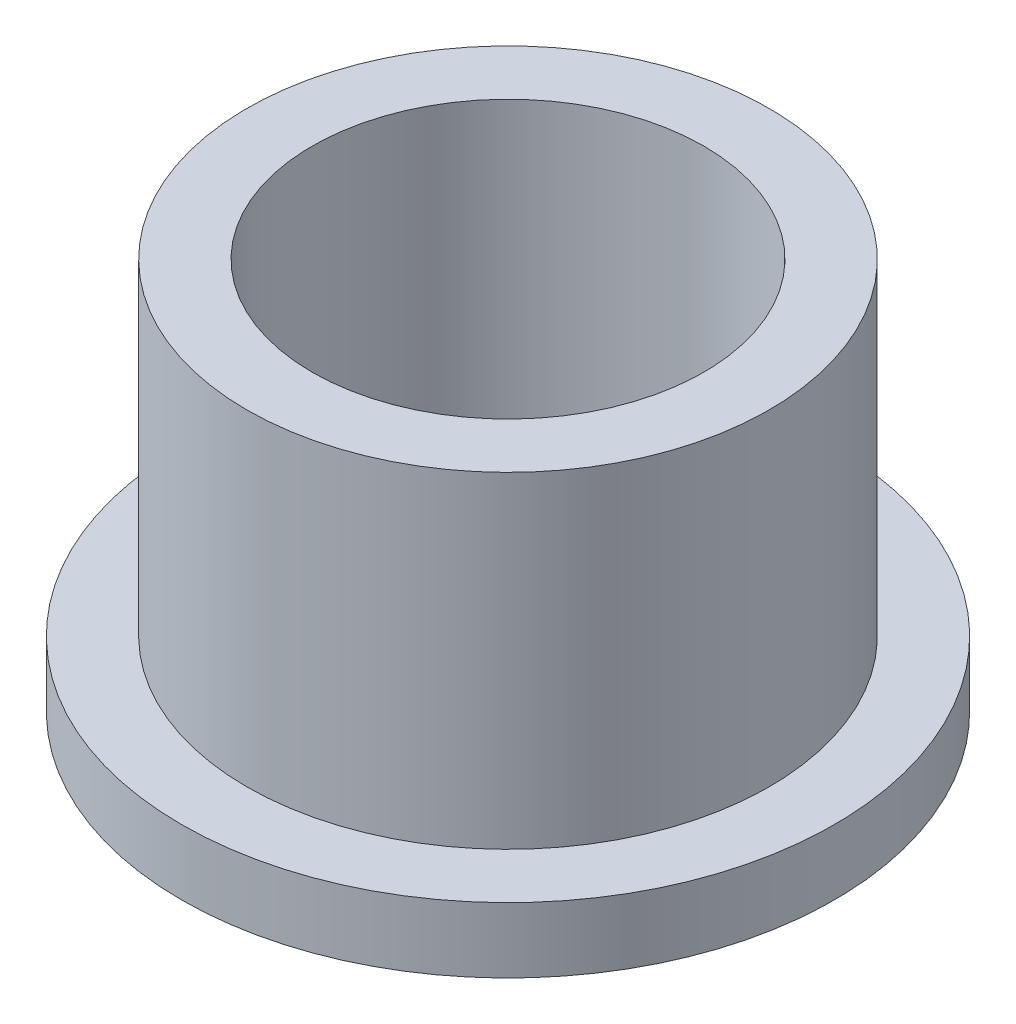
from build123d import *

# Parameters (mm, degrees)
TUBE_R              = 6.35
BOSS_EXTRUDE1_DEPTH = 9.525
FLANGE_R            = 7.9375
BOSS_EXTRUDE2_DEPTH = 1.5875
SHAFT_R             = 4.7625
CUT_EXTRUDE1_DEPTH  = 9.5875


with BuildPart() as part:
    # tube → Boss-Extrude1 (new body)
    with BuildSketch(Plane(origin=(0, 0, 0), x_dir=(1, 0, 0), z_dir=(0, 1, 0))):
        Circle(TUBE_R)
    extrude(amount=BOSS_EXTRUDE1_DEPTH)

    # Flange → Boss-Extrude2 (add)
    with BuildSketch(Plane(origin=(0, 0, 0), x_dir=(1, 0, 0), z_dir=(0, 1, 0))):
        Circle(FLANGE_R)
    extrude(amount=BOSS_EXTRUDE2_DEPTH)

    # shaft → Cut-Extrude1 (cut)
    with BuildSketch(Plane(origin=(0, 0, 0), x_dir=(1, 0, 0), z_dir=(0, 1, 0))):
        Circle(SHAFT_R)
    extrude(amount=CUT_EXTRUDE1_DEPTH, mode=Mode.SUBTRACT)


solid = part.part
